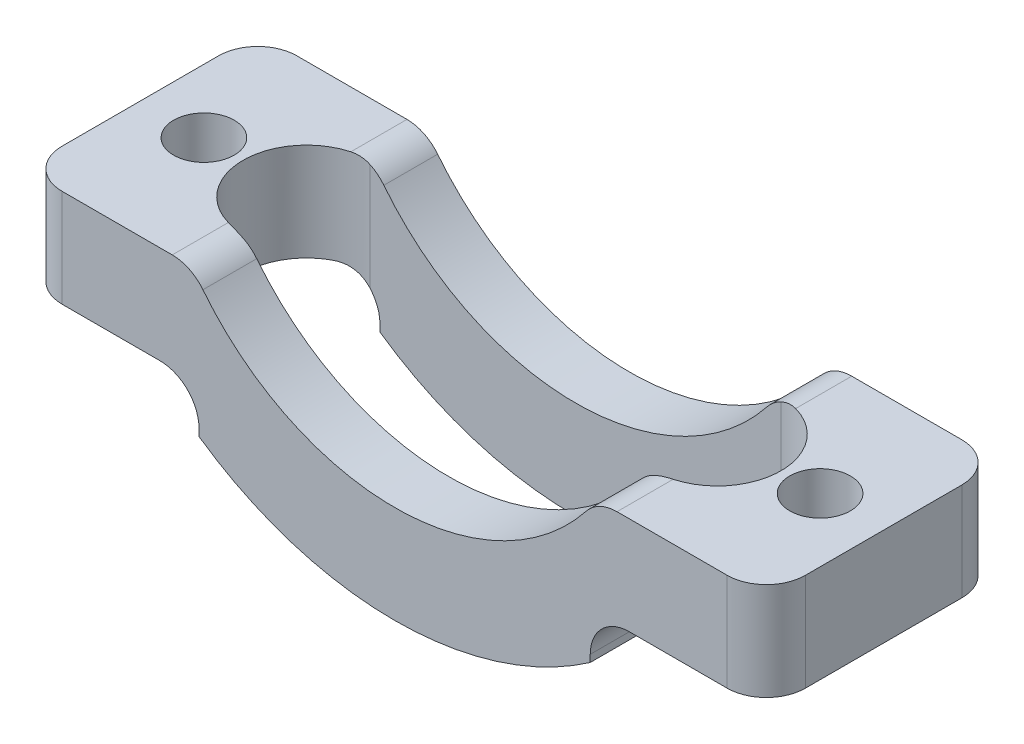
from build123d import *

# Parameters (mm, degrees)
EXTRUDE_1_DEPTH     = 12
FILLET_2_R          = 2
SKETCH_2_R          = 1.55
CUT_EXTRUDE_3_DEPTH = 12
SKETCH_3_R          = 3.25
CUT_EXTRUDE_4_DEPTH = 29.62434104


with BuildPart() as part:
    # Эскиз1 → Бобышка-Вытянуть1 (new body)
    with BuildSketch(Plane.XY):
        with BuildLine():
            Line((-14, -28), (-19, -28))
            Line((-19, -28), (-19, -33))
            Line((-19, -33), (-10, -33))
            Line((-10, -33), (-10, -35.361406616))
            ThreePointArc((-10, -35.361406616), (0, -38.5), (10, -35.361406616))
            Line((10, -35.361406616), (10, -33))
            Line((10, -33), (19, -33))
            Line((19, -33), (19, -28))
            Line((19, -28), (14, -28))
            Line((14, -28), (12.5, -28))
            Line((12.5, -28), (10.356157589, -28))
            ThreePointArc((10.356157589, -28), (0, -33.5), (-10.356157589, -28))
            Line((-10.356157589, -28), (-14, -28))
        make_face()
    extrude(amount=-EXTRUDE_1_DEPTH)

    # Скругление2
    fillet_2_edges = [part.edges().sort_by_distance(p)[0] for p in [
        (-19, -30.5, 0),
        (19, -30.5, 0),
        (-10, -33, -6),
        (-10.356157589, -28, -6),
        (10.356157589, -28, -6),
        (10, -33, -6),
        (19, -30.5, -12),
        (-19, -30.5, -12),
    ]]
    fillet(fillet_2_edges, radius=FILLET_2_R)

    # Эскиз2 → Вырез-Вытянуть3 (cut)
    with BuildSketch(Plane.XZ.offset(33)):
        with Locations(Location((15.75, -6, 0), (0, 0, 270))):
            Circle(SKETCH_2_R)
        with Locations(Location((-15.75, -6, 0), (0, 0, 270))):
            Circle(SKETCH_2_R)
    extrude(amount=-CUT_EXTRUDE_3_DEPTH, mode=Mode.SUBTRACT)

    # Эскиз3 → Вырез-Вытянуть4 (cut, through all)
    with BuildSketch(Plane(origin=(0, -20.77, 0), x_dir=(1, 0, 0), z_dir=(0, 1, 0))):
        with Locations((10.5, 6)):
            Circle(SKETCH_3_R)
        with BuildLine():
            Line((0, 9.25), (0, 2.75))
            Line((0, 2.75), (10.5, 2.75))
            ThreePointArc((10.5, 2.75), (7.25, 6), (10.5, 9.25))
            Line((10.5, 9.25), (0, 9.25))
        make_face()
        with BuildLine():
            Line((-10.5, 2.75), (0, 2.75))
            Line((0, 2.75), (0, 9.25))
            Line((0, 9.25), (-10.5, 9.25))
            ThreePointArc((-10.5, 9.25), (-8.201902961, 8.298097039), (-7.25, 6))
            ThreePointArc((-7.25, 6), (-8.201902961, 3.701902961), (-10.5, 2.75))
        make_face()
        with Locations((-10.5, 6)):
            Circle(SKETCH_3_R)
    extrude(amount=-CUT_EXTRUDE_4_DEPTH, mode=Mode.SUBTRACT)


solid = part.part
